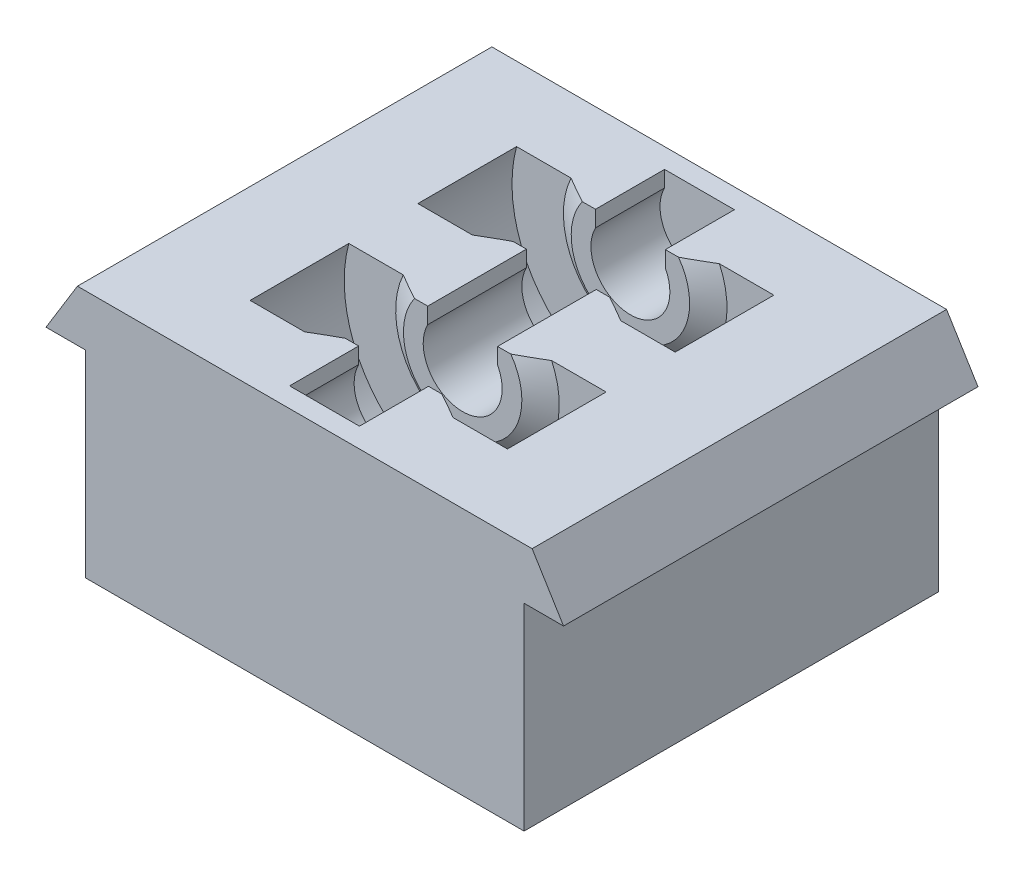
from build123d import *

# Parameters (mm, degrees)
BOSS_EXTRUDE1_DEPTH = 12.5
BOSS_EXTRUDE2_DEPTH = 7.5
BOSS_EXTRUDE3_DEPTH = 7.5
SKETCH5_W           = 44.45
SKETCH5_H           = 25
CUT_EXTRUDE1_DEPTH  = 10
CUT_EXTRUDE2_START  = -1.632728
SKETCH6_W           = 7.078863834
SKETCH6_H           = 10
CUT_EXTRUDE2_DEPTH  = 1.632728
BOSS_EXTRUDE4_DEPTH = 2
SKETCH8_R           = 1.5
CUT_EXTRUDE3_DEPTH  = 40


with BuildPart() as part:
    # Sketch1 → Boss-Extrude1 (new, symmetric)
    with BuildSketch(Plane.XY):
        with BuildLine():
            Line((-23.039431917, 7.577421516), (-13.039431917, 7.577421516))
            ThreePointArc((-13.039431917, 7.577421516), (0, -9.41875), (13.039431917, 7.577421516))
            Line((13.039431917, 7.577421516), (23.039431917, 7.577421516))
            Line((23.039431917, 7.577421516), (26.225, 2.38125))
            Line((26.225, 2.38125), (22.225, 2.38125))
            Line((22.225, 2.38125), (22.225, -17.61875))
            Line((22.225, -17.61875), (-22.225, -17.61875))
            Line((-22.225, -17.61875), (-22.225, 2.38125))
            Line((-22.225, 2.38125), (-26.225, 2.38125))
            Line((-26.225, 2.38125), (-23.039431917, 7.577421516))
        make_face()
    extrude(amount=BOSS_EXTRUDE1_DEPTH, both=True)

    # Sketch2 → Boss-Extrude2 (add)
    with BuildSketch(Plane.XY.offset(5)):
        with BuildLine():
            Line((-3.539431917, 5.944693506), (-3.539431917, 7.577421516))
            Line((-3.539431917, 7.577421516), (-13.039431917, 7.577421516))
            ThreePointArc((-13.039431917, 7.577421516), (0, -9.41875), (13.039431917, 7.577421516))
            Line((13.039431917, 7.577421516), (3.539431917, 7.577421516))
            Line((3.539431917, 7.577421516), (3.539431917, 5.944693506))
            ThreePointArc((3.539431917, 5.944693506), (0, 0.08125), (-3.539431917, 5.944693506))
        make_face()
    extrude(amount=BOSS_EXTRUDE2_DEPTH)

    # Sketch3 → Boss-Extrude3 (add)
    with BuildSketch(Plane.XY.offset(-5)):
        with BuildLine():
            Line((3.539431917, 7.577421516), (3.539431917, 5.944693506))
            ThreePointArc((3.539431917, 5.944693506), (0, 0.08125), (-3.539431917, 5.944693506))
            Line((-3.539431917, 5.944693506), (-3.539431917, 7.577421516))
            Line((-3.539431917, 7.577421516), (-13.039431917, 7.577421516))
            ThreePointArc((-13.039431917, 7.577421516), (0, -9.41875), (13.039431917, 7.577421516))
            Line((13.039431917, 7.577421516), (3.539431917, 7.577421516))
        make_face()
    extrude(amount=-BOSS_EXTRUDE3_DEPTH)

    # Sketch4 → Revolve1 (revolve)
    with BuildSketch(Plane(origin=(0, 4.08125, 0), x_dir=(1, 0, 0), z_dir=(0, 1, 0)), mode=Mode.PRIVATE) as revolve1_sk:
        Polygon((-4, -5), (-4, -3.5), (-6, -3.5), (-8.289431917, -5), align=None)
        Polygon((-4, 5), (-4, 3.5), (-6, 3.5), (-8.289431917, 5), align=None)
    revolve(revolve1_sk.sketch.rotate(Axis((0, 4.08125, 0), (0, 0, -1)), 27.765950742), axis=Axis((0, 4.08125, 0), (0, 0, -1)))

    # Sketch5 → Cut-Extrude1 (cut)
    with BuildSketch(Plane(origin=(0, 7.577421516, 0), x_dir=(1, 0, 0), z_dir=(0, 1, 0))):
        Rectangle(SKETCH5_W, SKETCH5_H)
    extrude(amount=CUT_EXTRUDE1_DEPTH, mode=Mode.SUBTRACT)

    # Sketch6 → Cut-Extrude2 (cut)
    with BuildSketch(Plane(origin=(0, 7.577421516, 0), x_dir=(1, 0, 0), z_dir=(0, 1, 0)).offset(CUT_EXTRUDE2_START)):
        Rectangle(SKETCH6_W, SKETCH6_H)
    extrude(amount=CUT_EXTRUDE2_DEPTH, mode=Mode.SUBTRACT)

    # Sketch7 → Boss-Extrude4 (add)
    with BuildSketch(Plane.XY.offset(12.5)):
        Polygon((-22.225, 2.38125), (-22.225, 7.577421516), (22.225, 7.577421516), (22.225, 2.38125), (22.225, -12.422578484), (-22.225, -12.422578484), align=None)
    boss_extrude4 = extrude(amount=-BOSS_EXTRUDE4_DEPTH)

    # Mirror1: Boss-Extrude4 across plane
    add(boss_extrude4.mirror(Plane.XY))

    # SurfaceCut1
    split(bisect_by=Plane(origin=(0, 0, -8.5), x_dir=(-1, 0, 0), z_dir=(0, 0, -1)), keep=Keep.BOTTOM)

    # Mirror2: part across plane


with BuildPart() as part_1:
    add(part.part)
    add(part.part.mirror(Plane(origin=(0, 0, -8.5), x_dir=(1, 0, 0), z_dir=(0, 0, -1))))

    # Sketch8 → Cut-Extrude3 (cut)
    with BuildSketch(Plane(origin=(0, 7.577421516, 0), x_dir=(1, 0, 0), z_dir=(0, 1, 0))):
        with Locations(Location((0, 0, 0), (0, 0, 180))):
            Circle(SKETCH8_R)
        with Locations(Location((0, 17, 0), (0, 0, 180))):
            Circle(SKETCH8_R)
    extrude(amount=-CUT_EXTRUDE3_DEPTH, mode=Mode.SUBTRACT)


solid = part_1.part
